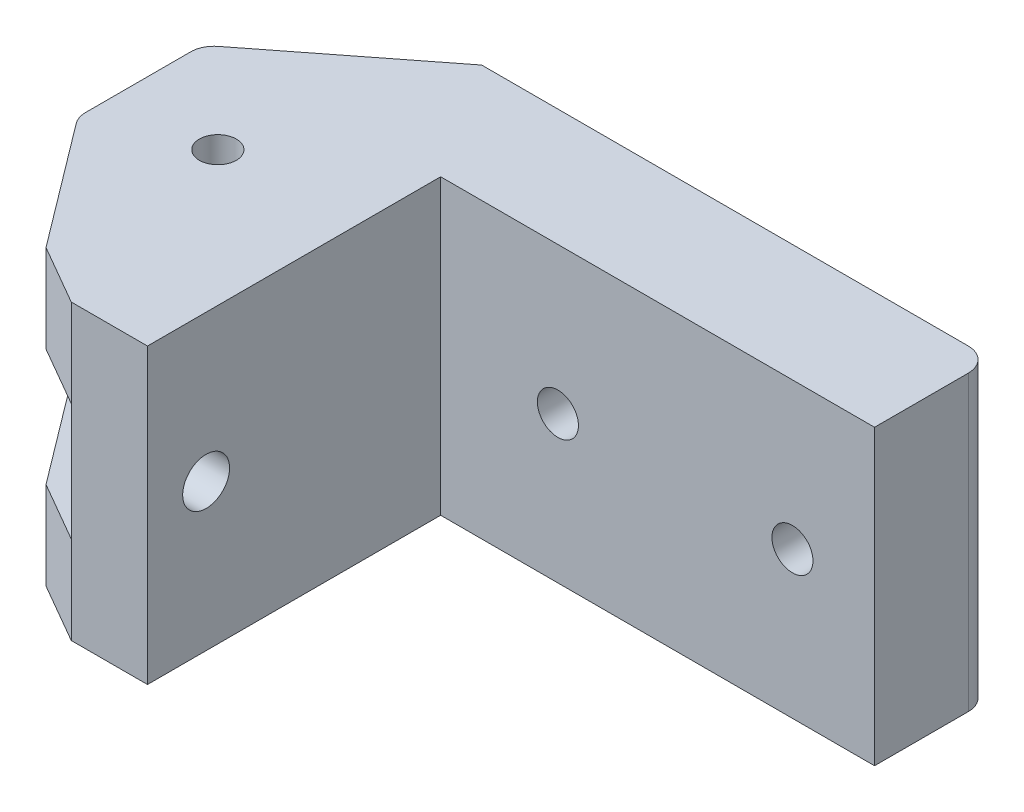
from build123d import *

# Parameters (mm, degrees)
SKETCH1_R               = 1.575
BOSS_EXTRUDE1_DEPTH     = 12.5
SKETCH2_W               = 13.385271969
SKETCH2_H               = 10
CUT_EXTRUDE1_DEPTH      = 36
SKETCH3_R               = 1.75
CUT_EXTRUDE2_DEPTH      = 25
SKETCH4_R               = 4
CUT_EXTRUDE3_DEPTH      = 4
FILLET1_R               = 2
SKETCH5_R               = 2
CUT_EXTRUDE4_DEPTH      = 10
SKETCH7_R               = 3.575
CUT_EXTRUDE5_DEPTH      = 3.5
SKETCH8_R               = 10
CUT_EXTRUDE6_DEPTH      = 5
CUT_EXTRUDE6_DEPTH_BACK = 5
CUT_EXTRUDE7_DEPTH      = 3


with BuildPart() as part:
    # Sketch1 → Boss-Extrude1 (new body, symmetric)
    with BuildSketch(Plane(origin=(0, 0, 0), x_dir=(1, 0, 0), z_dir=(0, 1, 0))):
        Polygon((0, 0), (-43.5, 0), (-56.885271969, -10.457720596), (-56.885271969, -21.057720596), (-48.596177418, -32.057720596), (-43.5, -35), (-37, -35), (-37, -10), (0, -10), align=None)
        with Locations((-48.5, -17.5)):
            Circle(SKETCH1_R, mode=Mode.SUBTRACT)
    extrude(amount=BOSS_EXTRUDE1_DEPTH, both=True)

    # Sketch2 → Cut-Extrude1 (cut, through all)
    with BuildSketch(Plane.XY.offset(35)):
        with Locations((-50.192635985, 0)):
            Rectangle(SKETCH2_W, SKETCH2_H)
    extrude(amount=-CUT_EXTRUDE1_DEPTH, mode=Mode.SUBTRACT)

    # Sketch3 → Cut-Extrude2 (cut)
    with BuildSketch(Plane.XY.offset(10)):
        with Locations((-27, 0)):
            Circle(SKETCH3_R)
        with Locations((-7, 0)):
            Circle(SKETCH3_R)
    extrude(amount=-CUT_EXTRUDE2_DEPTH, mode=Mode.SUBTRACT)

    # Sketch4 → Cut-Extrude3 (cut)
    with BuildSketch(Plane(origin=(0, 0, 0), x_dir=(-1, 0, 0), z_dir=(0, 0, -1))):
        with Locations((7, 0)):
            Circle(SKETCH4_R)
        with Locations((27, 0)):
            Circle(SKETCH4_R)
    extrude(amount=-CUT_EXTRUDE3_DEPTH, mode=Mode.SUBTRACT)

    # Fillet1
    fillet1_edges = [part.edges().sort_by_distance(p)[0] for p in [
        (-56.885271969, 8.75, 21.057720596),
        (-56.885271969, 8.75, 10.457720596),
        (0, 0, 0),
        (-56.885271969, -8.75, 21.057720596),
        (-56.885271969, -8.75, 10.457720596),
    ]]
    fillet(fillet1_edges, radius=FILLET1_R)

    # Sketch5 → Cut-Extrude4 (cut)
    with BuildSketch(Plane.ZY.offset(43.5)):
        with Locations((30, 0)):
            Circle(SKETCH5_R)
    extrude(amount=-CUT_EXTRUDE4_DEPTH, mode=Mode.SUBTRACT)

    # Sketch7 → Cut-Extrude5 (cut)
    with BuildSketch(Plane.ZY.offset(43.5)):
        with Locations((30, 0)):
            Circle(SKETCH7_R)
    extrude(amount=-CUT_EXTRUDE5_DEPTH, mode=Mode.SUBTRACT)

    # Sketch8 → Cut-Extrude6 (cut, two sides)
    with BuildSketch(Plane(origin=(0, 0, 0), x_dir=(1, 0, 0), z_dir=(0, 1, 0))) as cut_extrude6_sk:
        with Locations((-48.5, -17.5)):
            Circle(SKETCH8_R)
    extrude(amount=CUT_EXTRUDE6_DEPTH, mode=Mode.SUBTRACT)
    extrude(cut_extrude6_sk.sketch, amount=-CUT_EXTRUDE6_DEPTH_BACK, mode=Mode.SUBTRACT)

    # Sketch9 → Cut-Extrude7 (cut)
    with BuildSketch(Plane.XZ.offset(12.5)):
        Polygon((-46.800589834, 14.481390206), (-45.036102151, 17.462427479), (-46.735512318, 20.481037272), (-50.199410166, 20.518609794), (-51.963897849, 17.537572521), (-50.264487682, 14.518962728), align=None)
    extrude(amount=-CUT_EXTRUDE7_DEPTH, mode=Mode.SUBTRACT)


solid = part.part
